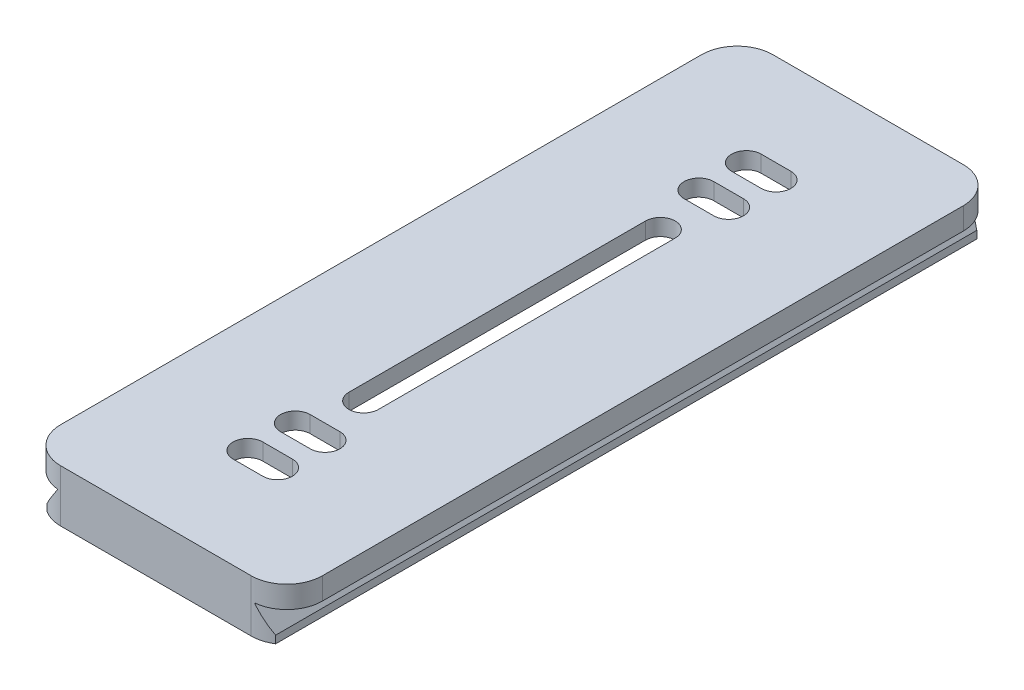
from build123d import *

# Parameters (mm, degrees)
SKETCH1_W           = 44.1
SKETCH1_H           = 120
BOSS_EXTRUDE1_DEPTH = 8.8
FILLET1_R           = 6
CUT_EXTRUDE1_DEPTH  = 121
CUT_EXTRUDE2_DEPTH  = 6


with BuildPart() as part:
    # Sketch1 → Boss-Extrude1 (new body)
    with BuildSketch(Plane(origin=(0, 0, 0), x_dir=(1, 0, 0), z_dir=(0, 1, 0))):
        Rectangle(SKETCH1_W, SKETCH1_H)
        with BuildLine():
            Line((-2.5, -25), (-2.5, 25))
            ThreePointArc((-2.5, 25), (0, 27.5), (2.5, 25))
            Line((2.5, 25), (2.5, -25))
            ThreePointArc((2.5, -25), (0, -27.5), (-2.5, -25))
        make_face(mode=Mode.SUBTRACT)
        with BuildLine():
            Line((-2.5, 36.5), (2.5, 36.5))
            ThreePointArc((2.5, 36.5), (5, 34), (2.5, 31.5))
            Line((2.5, 31.5), (-2.5, 31.5))
            ThreePointArc((-2.5, 31.5), (-5, 34), (-2.5, 36.5))
        make_face(mode=Mode.SUBTRACT)
        with BuildLine():
            Line((-2.5, 44.5), (2.5, 44.5))
            ThreePointArc((2.5, 44.5), (5, 42), (2.5, 39.5))
            Line((2.5, 39.5), (-2.5, 39.5))
            ThreePointArc((-2.5, 39.5), (-5, 42), (-2.5, 44.5))
        make_face(mode=Mode.SUBTRACT)
        with BuildLine():
            Line((-2.5, -44.5), (2.5, -44.5))
            ThreePointArc((2.5, -44.5), (5, -42), (2.5, -39.5))
            Line((2.5, -39.5), (-2.5, -39.5))
            ThreePointArc((-2.5, -39.5), (-5, -42), (-2.5, -44.5))
        make_face(mode=Mode.SUBTRACT)
        with BuildLine():
            Line((-2.5, -36.5), (2.5, -36.5))
            ThreePointArc((2.5, -36.5), (5, -34), (2.5, -31.5))
            Line((2.5, -31.5), (-2.5, -31.5))
            ThreePointArc((-2.5, -31.5), (-5, -34), (-2.5, -36.5))
        make_face(mode=Mode.SUBTRACT)
    extrude(amount=BOSS_EXTRUDE1_DEPTH)

    # Fillet1
    fillet1_edges = [part.edges().sort_by_distance(p)[0] for p in [
        (22.05, 4.4, 60),
        (-22.05, 4.4, 60),
        (-22.05, 4.4, -60),
        (22.05, 4.4, -60),
    ]]
    fillet(fillet1_edges, radius=FILLET1_R)

    # Sketch2 → Cut-Extrude1 (cut, through all)
    with BuildSketch(Plane.XY.offset(60)):
        Polygon((19.25, 0), (19.25, 1.270336268), (16.65, 4.958404732), (16.65, 5.1), (22.05, 5.1), (22.05, 0), align=None)
        Polygon((-22.05, 0), (-19.25, 0), (-19.25, 1.270336268), (-16.65, 4.958404732), (-16.65, 5.1), (-22.05, 5.1), align=None)
    extrude(amount=-CUT_EXTRUDE1_DEPTH, mode=Mode.SUBTRACT)

    # Sketch3 → Cut-Extrude2 (cut)
    with BuildSketch(Plane.XZ):
        with BuildLine():
            Line((-8.95, -55), (8.95, -55))
            ThreePointArc((8.95, -55), (12.485533906, -53.535533906), (13.95, -50))
            Line((13.95, -50), (13.95, 50))
            ThreePointArc((13.95, 50), (12.485533906, 53.535533906), (8.95, 55))
            Line((8.95, 55), (-8.95, 55))
            ThreePointArc((-8.95, 55), (-12.485533906, 53.535533906), (-13.95, 50))
            Line((-13.95, 50), (-13.95, -50))
            ThreePointArc((-13.95, -50), (-12.485533906, -53.535533906), (-8.95, -55))
        make_face()
    extrude(amount=-CUT_EXTRUDE2_DEPTH, mode=Mode.SUBTRACT)


solid = part.part
